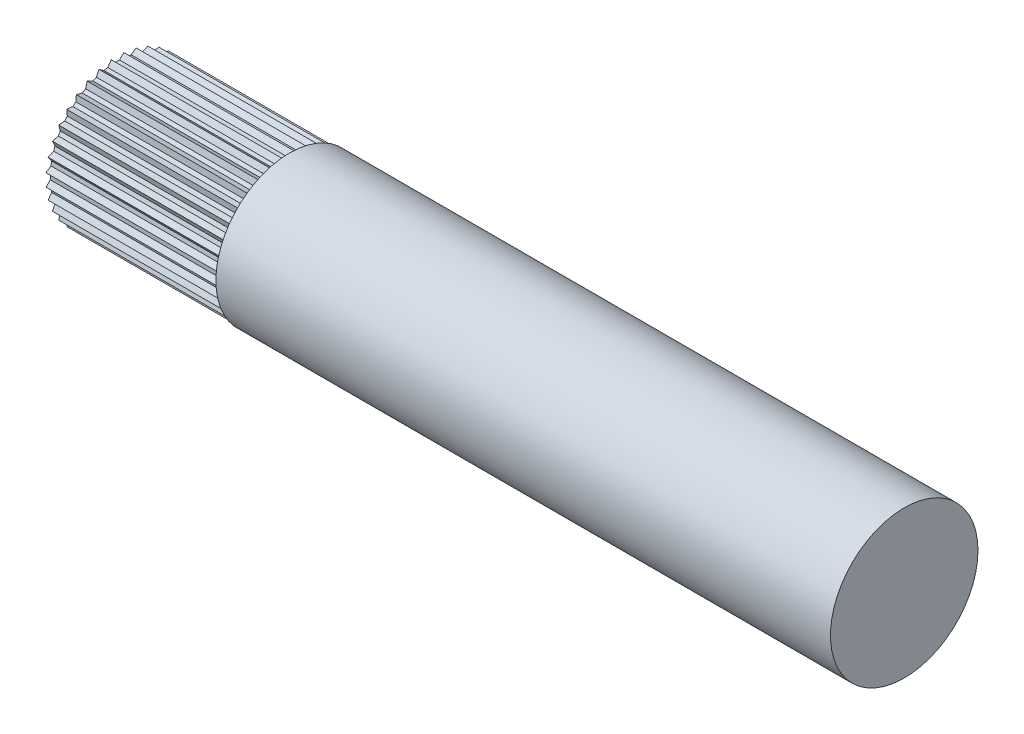
from build123d import *

# Parameters (mm, degrees)
SKETCH1_W           = 120.675
SKETCH1_H           = 1.5875
CUT_EXTRUDE2_START  = 19.25
SKETCH4_R           = 12.7
CUT_EXTRUDE2_DEPTH  = 22.225
SKETCH6_R           = 7.9375
BOSS_EXTRUDE1_DEPTH = 101.6
SKETCH7_R           = 23.308025585
CUT_EXTRUDE3_DEPTH  = 19.075


with BuildPart() as part:
    # Sketch1 → Revolve1 (revolve)
    with BuildSketch(Plane(origin=(0, 0, 0), x_dir=(1, 0, 0), z_dir=(0, 1, 0))):
        with Locations((79.5875, 8.73125)):
            Rectangle(SKETCH1_W, SKETCH1_H)
    revolve(axis=Axis((157.324, 0, 0), (-1, 0, 0)))

    # Sketch4 → Cut-Extrude2 (cut)
    with BuildSketch(Plane(origin=(0, 0, 0), x_dir=(0, 0, -1), z_dir=(1, 0, 0)).offset(CUT_EXTRUDE2_START)):
        Circle(SKETCH4_R)
        Polygon((-9.235721046, 0.808020891), (-8.681700155, 0.254), (-8.681700155, -0.254), (-9.235721046, -0.808020891), (-8.593912259, -1.257420242), (-8.505698985, -1.75770258), (-8.955098336, -2.399511367), (-8.245002688, -2.730634406), (-8.071256455, -3.207998257), (-8.402379494, -3.918093905), (-7.645572882, -4.120879625), (-7.391572882, -4.56082053), (-7.594358603, -5.317627141), (-6.813836213, -5.385914002), (-6.487300108, -5.775064579), (-6.555586968, -6.555586968), (-5.775064579, -6.487300108), (-5.385914002, -6.813836213), (-5.317627141, -7.594358603), (-4.56082053, -7.391572882), (-4.120879625, -7.645572882), (-3.918093905, -8.402379494), (-3.207998257, -8.071256455), (-2.730634406, -8.245002688), (-2.399511367, -8.955098336), (-1.75770258, -8.505698985), (-1.257420242, -8.593912259), (-0.808020891, -9.235721046), (-0.254, -8.681700155), (0.254, -8.681700155), (0.808020891, -9.235721046), (1.257420242, -8.593912259), (1.75770258, -8.505698985), (2.399511367, -8.955098336), (2.730634406, -8.245002688), (3.207998257, -8.071256455), (3.918093905, -8.402379494), (4.120879625, -7.645572882), (4.56082053, -7.391572882), (5.317627141, -7.594358603), (5.385914002, -6.813836213), (5.775064579, -6.487300108), (6.555586968, -6.555586968), (6.487300108, -5.775064579), (6.813836213, -5.385914002), (7.594358603, -5.317627141), (7.391572882, -4.56082053), (7.645572882, -4.120879625), (8.402379494, -3.918093905), (8.071256455, -3.207998257), (8.245002688, -2.730634406), (8.955098336, -2.399511367), (8.505698985, -1.75770258), (8.593912259, -1.257420242), (9.235721046, -0.808020891), (8.681700155, -0.254), (8.681700155, 0.254), (9.235721046, 0.808020891), (8.593912259, 1.257420242), (8.505698985, 1.75770258), (8.955098336, 2.399511367), (8.245002688, 2.730634406), (8.071256455, 3.207998257), (8.402379494, 3.918093905), (7.645572882, 4.120879625), (7.391572882, 4.56082053), (7.594358603, 5.317627141), (6.813836213, 5.385914002), (6.487300108, 5.775064579), (6.555586968, 6.555586968), (5.775064579, 6.487300108), (5.385914002, 6.813836213), (5.317627141, 7.594358603), (4.56082053, 7.391572882), (4.120879625, 7.645572882), (3.918093905, 8.402379494), (3.207998257, 8.071256455), (2.730634406, 8.245002688), (2.399511367, 8.955098336), (1.75770258, 8.505698985), (1.257420242, 8.593912259), (0.808020891, 9.235721046), (0.254, 8.681700155), (-0.254, 8.681700155), (-0.808020891, 9.235721046), (-1.257420242, 8.593912259), (-1.75770258, 8.505698985), (-2.399511367, 8.955098336), (-2.730634406, 8.245002688), (-3.207998257, 8.071256455), (-3.918093905, 8.402379494), (-4.120879625, 7.645572882), (-4.56082053, 7.391572882), (-5.317627141, 7.594358603), (-5.385914002, 6.813836213), (-5.775064579, 6.487300108), (-6.555586968, 6.555586968), (-6.487300108, 5.775064579), (-6.813836213, 5.385914002), (-7.594358603, 5.317627141), (-7.391572882, 4.56082053), (-7.645572882, 4.120879625), (-8.402379494, 3.918093905), (-8.071256455, 3.207998257), (-8.245002688, 2.730634406), (-8.955098336, 2.399511367), (-8.505698985, 1.75770258), (-8.593912259, 1.257420242), align=None, mode=Mode.SUBTRACT)
    extrude(amount=CUT_EXTRUDE2_DEPTH, mode=Mode.SUBTRACT)

    # Sketch6 → Boss-Extrude1 (add)
    with BuildSketch(Plane.ZY.offset(-19.25)):
        Circle(SKETCH6_R)
    extrude(amount=-BOSS_EXTRUDE1_DEPTH)

    # Sketch7 → Cut-Extrude3 (cut)
    with BuildSketch(Plane(origin=(120.85, 0, 0), x_dir=(0, 0, -1), z_dir=(1, 0, 0))):
        Circle(SKETCH7_R)
    extrude(amount=CUT_EXTRUDE3_DEPTH, mode=Mode.SUBTRACT)


solid = part.part
